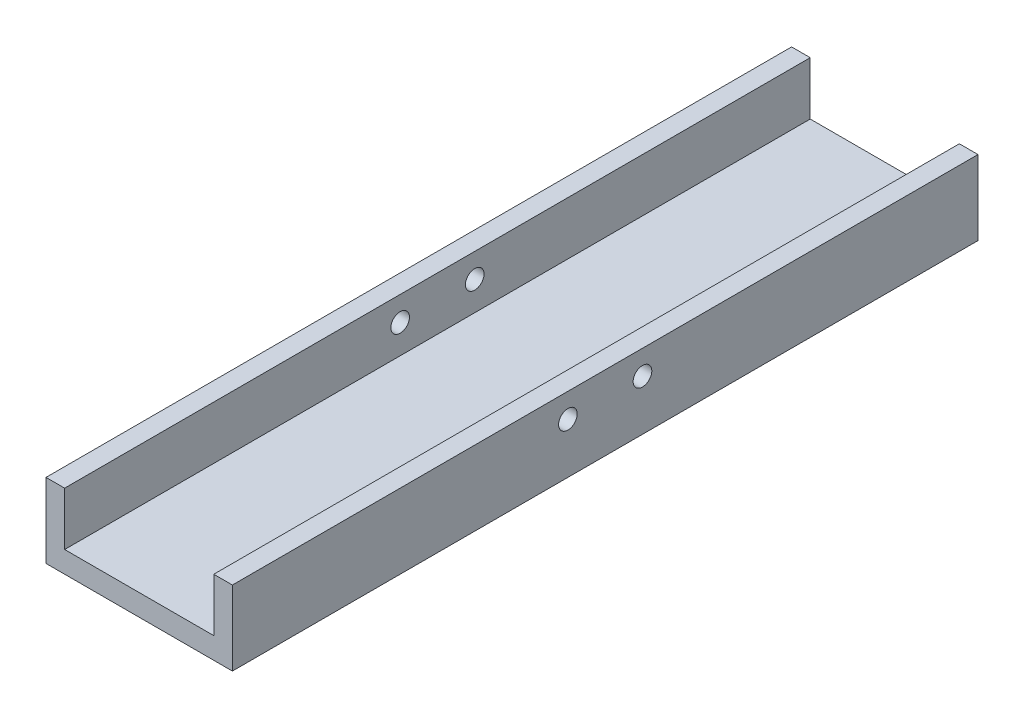
from build123d import *

# Parameters (mm, degrees)
SKIZZE1_W                            = 50
SKIZZE1_H                            = 20
AUFSATZ_LINEAR_AUSTRAGEN1_DEPTH      = 200
SKIZZE3_R                            = 2.5
SCHNITT_LINEAR_AUSTRAGEN1_DEPTH      = 46.342127859
SCHNITT_LINEAR_AUSTRAGEN1_DEPTH_BACK = 5.657872141
SCHNITT_LINEAR_START                 = 10
SKIZZE4_W                            = 40
SKIZZE4_H                            = 200
SCHNITT_LINEAR_AUSTRAGEN2_DEPTH      = 20


with BuildPart() as part:
    # Skizze1 → Aufsatz-Linear austragen1 (new body)
    with BuildSketch(Plane.XY):
        with Locations((20.342127859, -5.74485208)):
            Rectangle(SKIZZE1_W, SKIZZE1_H)
    extrude(amount=AUFSATZ_LINEAR_AUSTRAGEN1_DEPTH)

    # Skizze3 → Schnitt-Linear austragen1 (cut, two sides)
    with BuildSketch(Plane(origin=(0, 0, 0), x_dir=(0, 0, -1), z_dir=(1, 0, 0))) as schnitt_linear_austragen1_sk:
        with Locations((-90, -2.24485208)):
            Circle(SKIZZE3_R)
        with Locations((-110, -2.24485208)):
            Circle(SKIZZE3_R)
    extrude(amount=SCHNITT_LINEAR_AUSTRAGEN1_DEPTH, mode=Mode.SUBTRACT)
    extrude(schnitt_linear_austragen1_sk.sketch, amount=-SCHNITT_LINEAR_AUSTRAGEN1_DEPTH_BACK, mode=Mode.SUBTRACT)

    # Skizze4 → Schnitt-Linear austragen2 (cut)
    with BuildSketch(Plane(origin=(0, 0, 0), x_dir=(1, 0, 0), z_dir=(0, 1, 0)).offset(SCHNITT_LINEAR_START)):
        with Locations((20.342127859, -100)):
            Rectangle(SKIZZE4_W, SKIZZE4_H)
    extrude(amount=-SCHNITT_LINEAR_AUSTRAGEN2_DEPTH, mode=Mode.SUBTRACT)


solid = part.part
